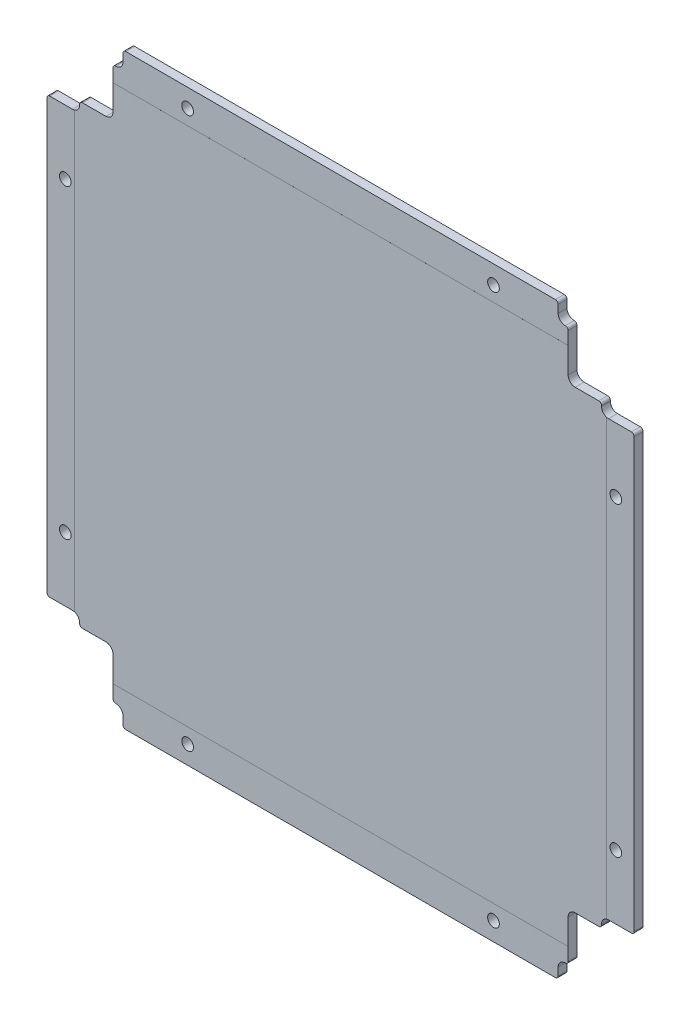
from build123d import *

# Parameters (mm, degrees)
SKETCH1_W                 = 106
SKETCH1_H                 = 106
MAINOUTLINE_DEPTH         = 1.6
SKETCH4_W                 = 11.7
SKETCH4_H                 = 11.7
RAILCUTOUTS_DEPTH         = 2.6
FILLETCUTOUTS_START       = -2.6
SKETCH13_W                = 5.7
SKETCH13_H                = 1.9
SKETCH13_W_2              = 1.8
SKETCH13_H_2              = 3
FILLETCUTOUTS_DEPTH       = 3.6
SMOOTHCORNER_DEPTH        = 10
MIRROR2_COPY_1_SKETCH_W   = 11.7
MIRROR2_COPY_1_SKETCH_H   = 11.7
MIRROR2_COPY_1_DEPTH      = 2.6
MIRROR2_START             = -2.6
MIRROR2_COPY_2_SKETCH_W   = 5.7
MIRROR2_COPY_2_SKETCH_H   = 1.9
MIRROR2_COPY_2_SKETCH_W_2 = 1.8
MIRROR2_COPY_2_SKETCH_H_2 = 3
MIRROR2_COPY_2_DEPTH      = 3.6
MIRROR2_COPY_3_DEPTH      = 10
MIRROR2_COPY_4_SKETCH_W   = 11.7
MIRROR2_COPY_4_SKETCH_H   = 11.7
MIRROR2_COPY_4_DEPTH      = 2.6
MIRROR2_COPY_5_SKETCH_W   = 5.7
MIRROR2_COPY_5_SKETCH_H   = 1.9
MIRROR2_COPY_5_SKETCH_W_2 = 1.8
MIRROR2_COPY_5_SKETCH_H_2 = 3
MIRROR2_COPY_5_DEPTH      = 3.6
FILLET10_R                = 0.5
M2_CLEARANCE_HOLE1_D      = 2.1
SKETCH16_W                = 90
SKETCH16_H                = 6.2
SKETCH16_W_2              = 5.2
SKETCH16_H_2              = 90
CUT_EXTRUDE6_DEPTH        = 0.001
SKETCH24_OUTSIDE_W        = 137.984
SKETCH24_OUTSIDE_H        = 137.984
SKETCH24_OUTSIDE_W_2      = 105.6
SKETCH24_OUTSIDE_H_2      = 105.6
CUT_EXTRUDE19_DEPTH       = 2.6
FILLET7_R                 = 0.5


with BuildPart() as part:
    # Sketch1 → mainOutline (new body)
    with BuildSketch(Plane.XY):
        Rectangle(SKETCH1_W, SKETCH1_H)
    extrude(amount=MAINOUTLINE_DEPTH)

    # Sketch4 → railCutouts (cut, through all)
    with BuildSketch(Plane(origin=(0, 0, 0), x_dir=(-1, 0, 0), z_dir=(0, 0, -1))):
        with Locations((47.15, 47.15)):
            Rectangle(SKETCH4_W, SKETCH4_H)
    railcutouts = extrude(amount=-RAILCUTOUTS_DEPTH, mode=Mode.SUBTRACT)

    # Sketch13 → filletCutouts (cut)
    with BuildSketch(Plane(origin=(0, 0, 0), x_dir=(-1, 0, 0), z_dir=(0, 0, -1)).offset(FILLETCUTOUTS_START)):
        with Locations((50.15, 40.35)):
            Rectangle(SKETCH13_W, SKETCH13_H)
        with Locations((40.4, 51.5)):
            Rectangle(SKETCH13_W_2, SKETCH13_H_2)
    filletcutouts = extrude(amount=FILLETCUTOUTS_DEPTH, mode=Mode.SUBTRACT)

    # Sketch27 → smoothCorner (cut)
    with BuildSketch(Plane.XY.offset(1.6)):
        with BuildLine():
            Line((-40.928025612, 42.198025612), (-40.928025612, 49.628025612))
            Line((-40.928025612, 49.628025612), (-40.398025612, 49.628025612))
            ThreePointArc((-40.398025612, 49.628025612), (-39.5, 50), (-39.128025612, 50.898025612))
            Line((-39.128025612, 50.898025612), (-39.128025612, 53))
            Line((-39.128025612, 53), (-53, 53))
            Line((-53, 53), (-53, 39.028025612))
            Line((-53, 39.028025612), (-48.198025612, 39.028025612))
            ThreePointArc((-48.198025612, 39.028025612), (-47.3, 39.4), (-46.928025612, 40.298025612))
            Line((-46.928025612, 40.298025612), (-46.928025612, 40.928025612))
            Line((-46.928025612, 40.928025612), (-42.198025612, 40.928025612))
            ThreePointArc((-42.198025612, 40.928025612), (-41.3, 41.3), (-40.928025612, 42.198025612))
        make_face()
    smoothcorner = extrude(amount=-SMOOTHCORNER_DEPTH, mode=Mode.SUBTRACT)

    # Mirror1: railCutouts, filletCutouts, smoothCorner across plane
    add(railcutouts.mirror(Plane(origin=(0, 0, 0), x_dir=(0, 0, 1), z_dir=(1, 0, 0))), mode=Mode.SUBTRACT)
    add(filletcutouts.mirror(Plane(origin=(0, 0, 0), x_dir=(0, 0, 1), z_dir=(1, 0, 0))), mode=Mode.SUBTRACT)
    add(smoothcorner.mirror(Plane(origin=(0, 0, 0), x_dir=(0, 0, 1), z_dir=(1, 0, 0))), mode=Mode.SUBTRACT)

    # Mirror2: smoothCorner across plane
    add(smoothcorner.mirror(Plane.ZX), mode=Mode.SUBTRACT)

    # Mirror2 copy 1 sketch → Mirror2 copy 1 (cut, through all)
    with BuildSketch(Plane(origin=(0, 0, 0), x_dir=(1, 0, 0), z_dir=(0, 0, -1))):
        with Locations((47.15, 47.15)):
            Rectangle(MIRROR2_COPY_1_SKETCH_W, MIRROR2_COPY_1_SKETCH_H)
    extrude(amount=-MIRROR2_COPY_1_DEPTH, mode=Mode.SUBTRACT)

    # Mirror2 copy 2 sketch → Mirror2 copy 2 (cut)
    with BuildSketch(Plane(origin=(0, 0, 0), x_dir=(1, 0, 0), z_dir=(0, 0, -1)).offset(MIRROR2_START)):
        with Locations((50.15, 40.35)):
            Rectangle(MIRROR2_COPY_2_SKETCH_W, MIRROR2_COPY_2_SKETCH_H)
        with Locations((40.4, 51.5)):
            Rectangle(MIRROR2_COPY_2_SKETCH_W_2, MIRROR2_COPY_2_SKETCH_H_2)
    extrude(amount=MIRROR2_COPY_2_DEPTH, mode=Mode.SUBTRACT)

    # Mirror2 copy 3 sketch → Mirror2 copy 3 (cut)
    with BuildSketch(Plane(origin=(0, 0, 1.6), x_dir=(-1, 0, 0), z_dir=(0, 0, 1))):
        with BuildLine():
            Line((-40.928025612, 42.198025612), (-40.928025612, 49.628025612))
            Line((-40.928025612, 49.628025612), (-40.398025612, 49.628025612))
            ThreePointArc((-40.398025612, 49.628025612), (-39.5, 50), (-39.128025612, 50.898025612))
            Line((-39.128025612, 50.898025612), (-39.128025612, 53))
            Line((-39.128025612, 53), (-53, 53))
            Line((-53, 53), (-53, 39.028025612))
            Line((-53, 39.028025612), (-48.198025612, 39.028025612))
            ThreePointArc((-48.198025612, 39.028025612), (-47.3, 39.4), (-46.928025612, 40.298025612))
            Line((-46.928025612, 40.298025612), (-46.928025612, 40.928025612))
            Line((-46.928025612, 40.928025612), (-42.198025612, 40.928025612))
            ThreePointArc((-42.198025612, 40.928025612), (-41.3, 41.3), (-40.928025612, 42.198025612))
        make_face()
    extrude(amount=-MIRROR2_COPY_3_DEPTH, mode=Mode.SUBTRACT)

    # Mirror2 copy 4 sketch → Mirror2 copy 4 (cut, through all)
    with BuildSketch(Plane(origin=(0, 0, 0), x_dir=(-1, 0, 0), z_dir=(0, 0, -1))):
        with Locations((47.15, -47.15)):
            Rectangle(MIRROR2_COPY_4_SKETCH_W, MIRROR2_COPY_4_SKETCH_H)
    extrude(amount=-MIRROR2_COPY_4_DEPTH, mode=Mode.SUBTRACT)

    # Mirror2 copy 5 sketch → Mirror2 copy 5 (cut)
    with BuildSketch(Plane(origin=(0, 0, 0), x_dir=(-1, 0, 0), z_dir=(0, 0, -1)).offset(MIRROR2_START)):
        with Locations((50.15, -40.35)):
            Rectangle(MIRROR2_COPY_5_SKETCH_W, MIRROR2_COPY_5_SKETCH_H)
        with Locations((40.4, -51.5)):
            Rectangle(MIRROR2_COPY_5_SKETCH_W_2, MIRROR2_COPY_5_SKETCH_H_2)
    extrude(amount=MIRROR2_COPY_5_DEPTH, mode=Mode.SUBTRACT)

    # Fillet10
    fillet10_edges = [part.edges().sort_by_distance(p)[0] for p in [
        (40.928025612, 49.628025612, 0.8),
        (46.928025612, 40.928025612, 0.8),
        (46.928025612, -40.928025612, 0.8),
        (40.928025612, -49.628025612, 0.8),
        (-40.928025612, -49.628025612, 0.8),
        (-46.928025612, -40.928025612, 0.8),
        (-46.928025612, 40.928025612, 0.8),
        (-40.928025612, 49.628025612, 0.8),
    ]]
    fillet(fillet10_edges, radius=FILLET10_R)

    # M2 Clearance Hole1 (through all)
    with Locations(Plane(origin=(0, 0, 0), x_dir=(-1, 0, 0), z_dir=(0, 0, -1))):
        with Locations((49.5, -27.5), (27.5, -49.5), (-49.5, -27.5), (-27.5, -49.5), (-27.5, 49.5), (-49.5, 27.5), (27.5, 49.5), (49.5, 27.5)):
            Hole(M2_CLEARANCE_HOLE1_D / 2)

    # Sketch16 → Cut-Extrude6 (cut)
    with BuildSketch(Plane.XY.offset(1.6)):
        with Locations((0, -49.9)):
            Rectangle(SKETCH16_W, SKETCH16_H)
        with Locations((0, 49.9)):
            Rectangle(SKETCH16_W, SKETCH16_H)
        with Locations((-50.4, 0)):
            Rectangle(SKETCH16_W_2, SKETCH16_H_2)
        with Locations((50.4, 0)):
            Rectangle(SKETCH16_W_2, SKETCH16_H_2)
    extrude(amount=-CUT_EXTRUDE6_DEPTH, mode=Mode.SUBTRACT)

    # Sketch24 outside → Cut-Extrude19 (cut, through all)
    with BuildSketch(Plane.XY.offset(1.6)):
        Rectangle(SKETCH24_OUTSIDE_W, SKETCH24_OUTSIDE_H)
        Rectangle(SKETCH24_OUTSIDE_W_2, SKETCH24_OUTSIDE_H_2, mode=Mode.SUBTRACT)
    extrude(amount=-CUT_EXTRUDE19_DEPTH, mode=Mode.SUBTRACT)

    # Fillet7
    fillet7_edges = [part.edges().sort_by_distance(p)[0] for p in [
        (-52.8, -39.028025612, 0.7995),
        (-39.128025612, -52.8, 0.7995),
        (52.8, -39.028025612, 0.7995),
        (39.128025612, 52.8, 0.7995),
        (52.8, 39.028025612, 0.7995),
        (39.128025612, -52.8, 0.7995),
        (-52.8, 39.028025612, 0.7995),
        (-39.128025612, 52.8, 0.7995),
    ]]
    fillet(fillet7_edges, radius=FILLET7_R)


solid = part.part
